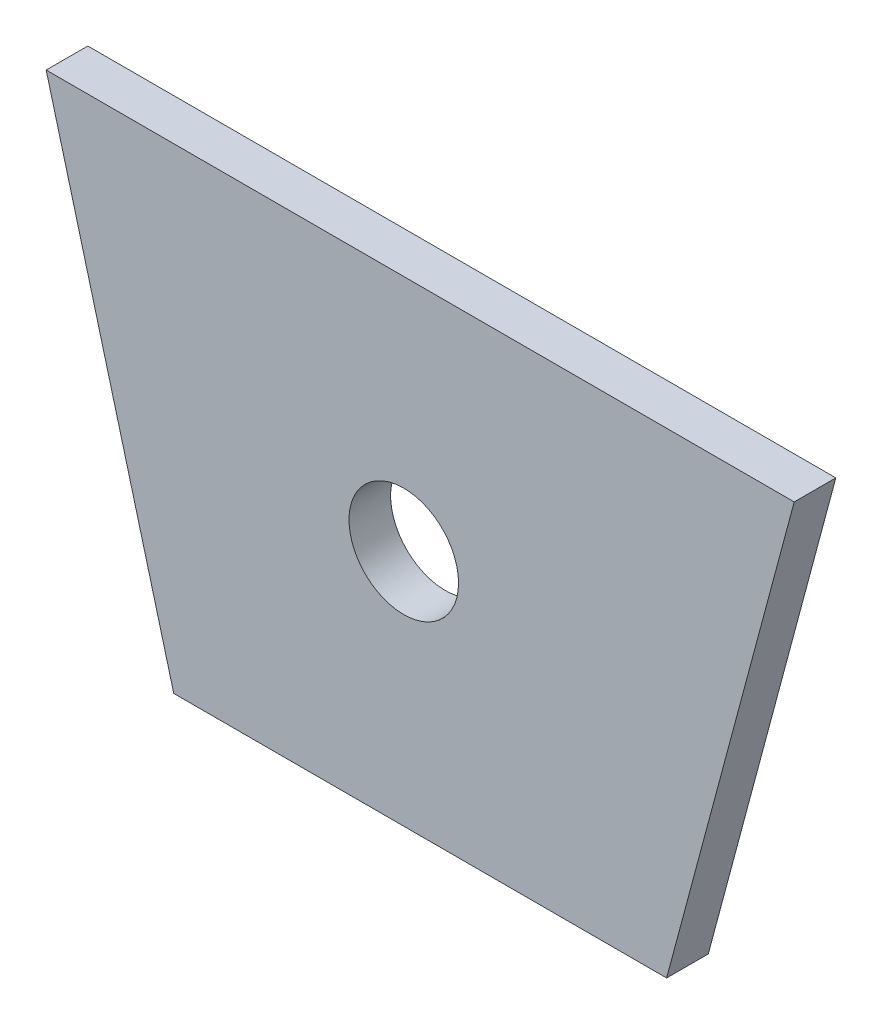
from build123d import *

# Parameters (mm, degrees)
BOSS_EXTRUDE1_DEPTH = 4.826
SKETCH4_R           = 6.35
CUT_EXTRUDE5_DEPTH  = 5.826


with BuildPart() as part:
    # Sketch1 → Boss-Extrude1 (new body)
    with BuildSketch(Plane.XY):
        Polygon((-26.67, -22.21179672), (30.48, -22.21179672), (45.271508428, 32.990864252), (-41.461508428, 32.990864252), align=None)
    extrude(amount=BOSS_EXTRUDE1_DEPTH)

    # Sketch4 → Cut-Extrude5 (cut, through all)
    with BuildSketch(Plane.XY):
        with Locations((0, 5.389533766)):
            Circle(SKETCH4_R)
    extrude(amount=CUT_EXTRUDE5_DEPTH, mode=Mode.SUBTRACT)


solid = part.part
